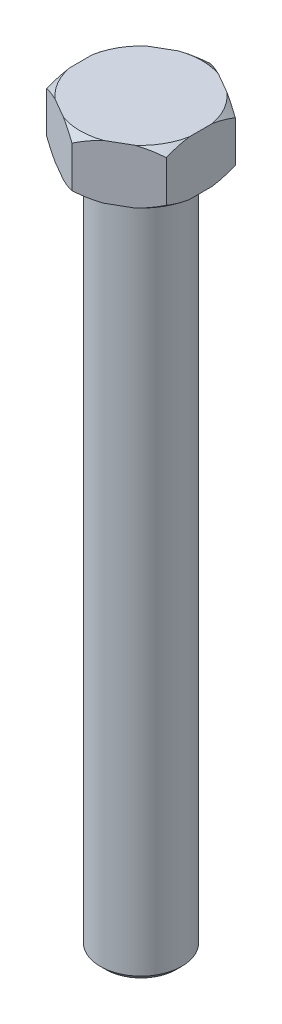
from build123d import *

# Parameters (mm, degrees)
BOSS_EXTRUDE1_DEPTH = 10
SKETCH2_R           = 7.5
BOSS_EXTRUDE2_DEPTH = 126
CHAMFER1_SIZE       = 1


with BuildPart() as part:
    # Sketch1 → Boss-Extrude1 (new body)
    with BuildSketch(Plane(origin=(0, 0, 0), x_dir=(1, 0, 0), z_dir=(0, 1, 0))):
        Polygon((-11, 6.350852961), (-11, -6.350852961), (0, -12.701705922), (11, -6.350852961), (11, 6.350852961), (0, 12.701705922), align=None)
    extrude(amount=BOSS_EXTRUDE1_DEPTH)

    # Sketch2 → Boss-Extrude2 (add)
    with BuildSketch(Plane.XZ):
        Circle(SKETCH2_R)
    extrude(amount=BOSS_EXTRUDE2_DEPTH)

    # Chamfer1
    chamfer1_edges = [part.edges().sort_by_distance(p)[0] for p in [
        (-7.5, -126, 0),
    ]]
    chamfer(chamfer1_edges, length=CHAMFER1_SIZE)

    # Sketch4 → Cut-Revolve2 (revolve, cut)
    with BuildSketch(Plane(origin=(0, 0, 0), x_dir=(0, 0, -1), z_dir=(1, 0, 0))):
        Polygon((12.701705922, 10), (12.701705922, 8.8), (11.201705922, 10), align=None)
        Polygon((12.701705922, 1.2), (12.701705922, 0), (11.201705922, 0), align=None)
    revolve(axis=Axis((0, 0, 0), (0, 1, 0)), mode=Mode.SUBTRACT)


solid = part.part
